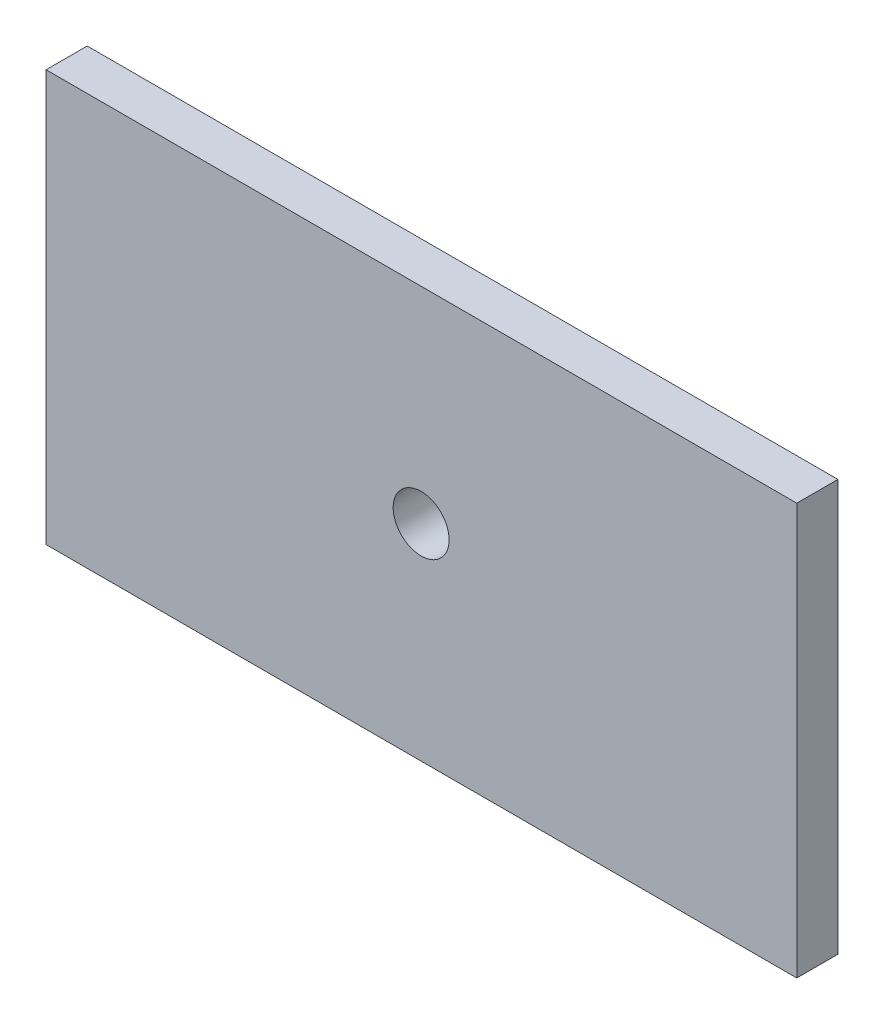
from build123d import *

# Parameters (mm, degrees)
SKETCH1_W          = 6.35
SKETCH1_H          = 63.5
EXTRUDE1_DEPTH     = 115.91798
SKETCH2_R          = 4.318
CUT_EXTRUDE1_DEPTH = 12.7


with BuildPart() as part:
    # Sketch1 → Extrude1 (new body)
    with BuildSketch(Plane(origin=(0, 0, 0), x_dir=(0, 0, -1), z_dir=(1, 0, 0))):
        with Locations((3.175, 31.75)):
            Rectangle(SKETCH1_W, SKETCH1_H)
    extrude(amount=EXTRUDE1_DEPTH)

    # Sketch2 → Cut-Extrude1 (cut)
    with BuildSketch(Plane.XY):
        with Locations((57.912, 31.75)):
            Circle(SKETCH2_R)
    extrude(amount=-CUT_EXTRUDE1_DEPTH, mode=Mode.SUBTRACT)


solid = part.part
